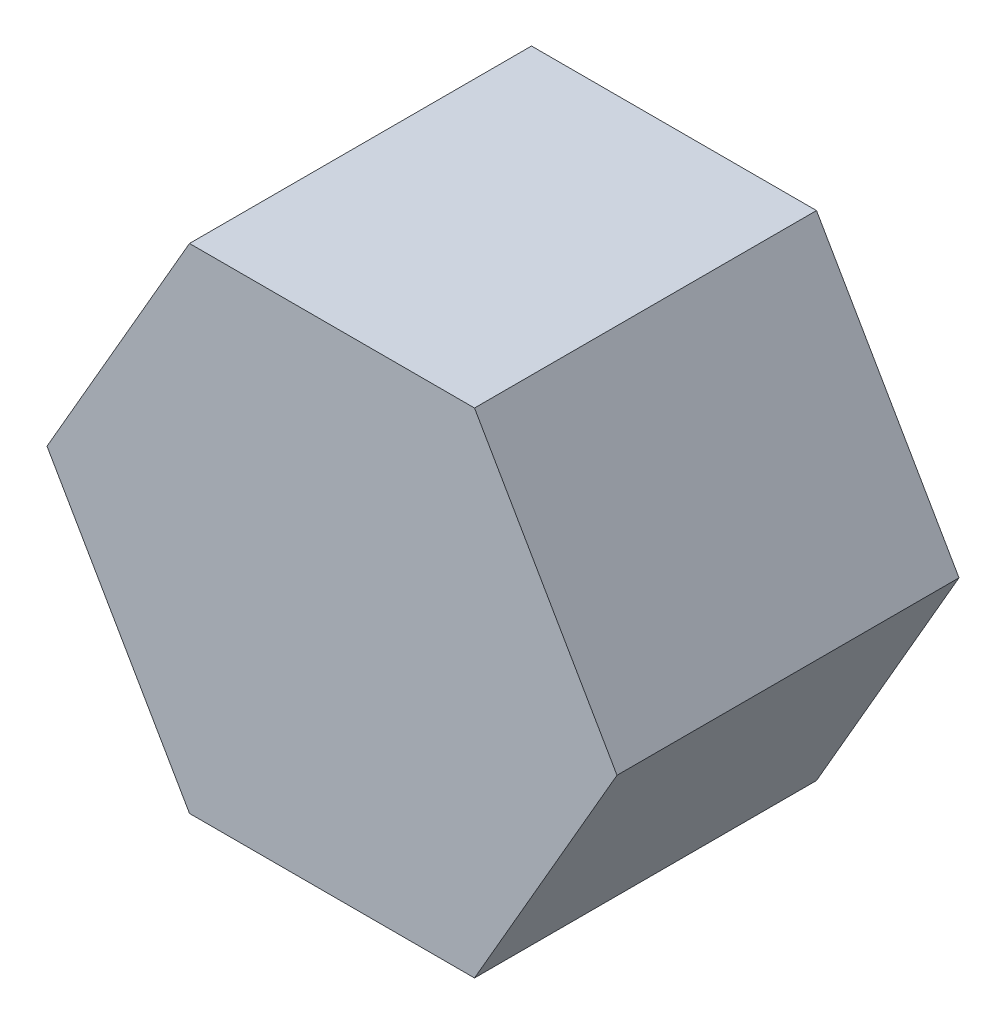
from build123d import *

# Parameters (mm, degrees)
ESTRUSIONE_ESTRUSIONE1_DEPTH = 30


with BuildPart() as part:
    # Schizzo1 → Estrusione-Estrusione1 (new body)
    with BuildSketch(Plane.XY):
        Polygon((-12.5, -21.650635095), (12.5, -21.650635095), (25, 0), (12.5, 21.650635095), (-12.5, 21.650635095), (-25, 0), align=None)
    extrude(amount=ESTRUSIONE_ESTRUSIONE1_DEPTH)


solid = part.part
